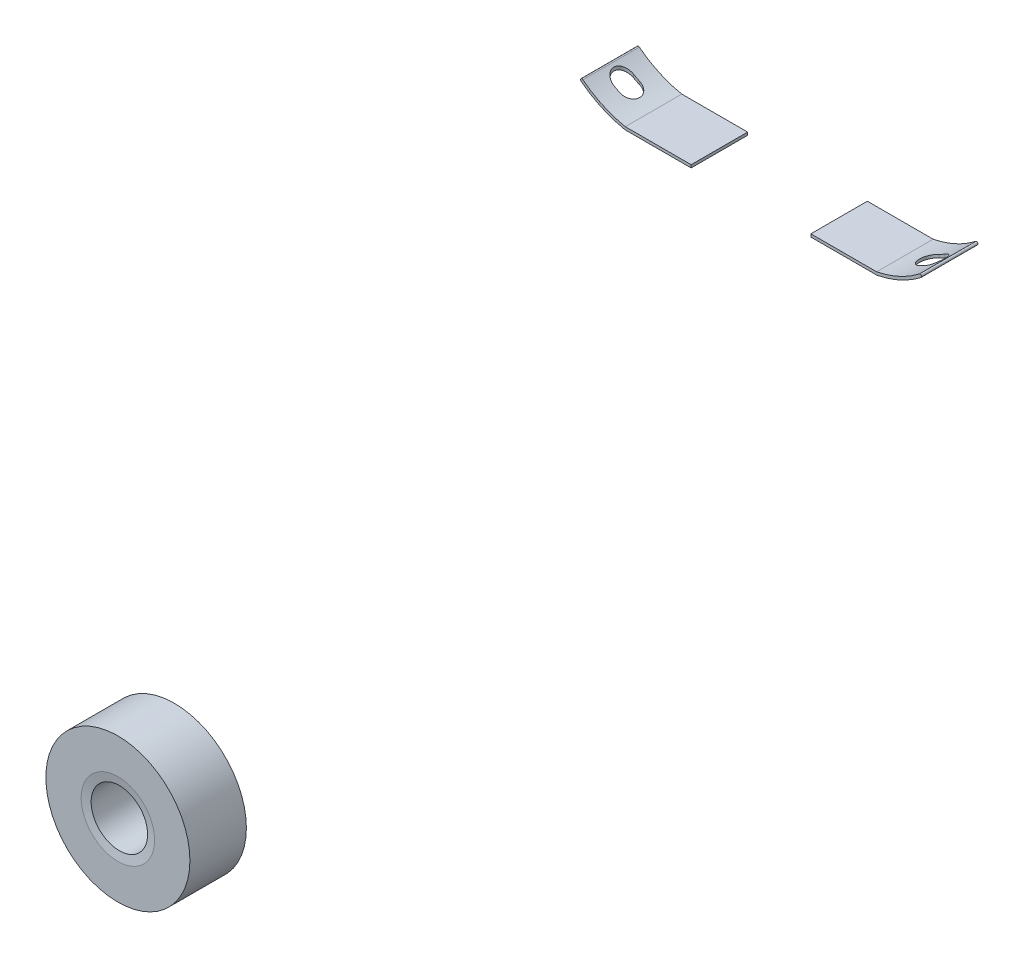
from build123d import *

# Parameters (mm, degrees)
BOSS_EXTRUDE1_DEPTH   = 2
BOSS_EXTRUDE1_2_DEPTH = 2
CUT_EXTRUDE1_DEPTH    = 2
SKETCH3_R             = 2.55
SKETCH3_R_2           = 1
BOSS_EXTRUDE2_DEPTH   = 2
CHAMFER1_SIZE         = 0.3
CHAMFER1_SIZE2        = 0.052898094


with BuildPart() as part:
    # Sketch1 → Boss-Extrude1 (new body)
    with BuildSketch(Plane.XY):
        with BuildLine():
            Line((2.119201361, 7.695095724), (4.458497719, 7.695095724))
            ThreePointArc((4.458497719, 7.695095724), (5.28034288, 7.957709004), (6.018106177, 8.40503497))
            ThreePointArc((6.018106177, 8.40503497), (6.026743298, 8.475216166), (5.956562103, 8.483853287))
            ThreePointArc((5.956562103, 8.483853287), (5.243250103, 8.05070086), (4.448831418, 7.795095724))
            Line((4.448831418, 7.795095724), (2.119201361, 7.795095724))
            Line((2.119201361, 7.795095724), (2.119201361, 7.695095724))
        make_face()
    extrude(amount=BOSS_EXTRUDE1_DEPTH)


with BuildPart() as body_2:
    # Sketch1 → Boss-Extrude1 2 (new body)
    with BuildSketch(Plane.XY):
        with BuildLine():
            Line((-2.119201361, 7.695095724), (-2.119201361, 7.795095724))
            Line((-2.119201361, 7.795095724), (-4.448831418, 7.795095724))
            ThreePointArc((-4.448831418, 7.795095724), (-5.243250103, 8.05070086), (-5.956562103, 8.483853287))
            ThreePointArc((-5.956562103, 8.483853287), (-6.026743298, 8.475216166), (-6.018106177, 8.40503497))
            ThreePointArc((-6.018106177, 8.40503497), (-5.28034288, 7.957709004), (-4.458497719, 7.695095724))
            Line((-4.458497719, 7.695095724), (-2.119201361, 7.695095724))
        make_face()
    extrude(amount=BOSS_EXTRUDE1_2_DEPTH)


with BuildPart() as cut_extrude1_tool:
    # Sketch2 → Cut-Extrude1 (new body)
    with BuildSketch(Plane.XZ.offset(-7.695095724)):
        with BuildLine():
            Line((5.30218152, 0.638571522), (5.512812284, 0.638571522))
            ThreePointArc((5.512812284, 0.638571522), (5.862812284, 0.988571522), (5.512812284, 1.338571522))
            Line((5.512812284, 1.338571522), (5.30218152, 1.338571522))
            ThreePointArc((5.30218152, 1.338571522), (4.95218152, 0.988571522), (5.30218152, 0.638571522))
        make_face()
        with BuildLine():
            Line((-5.30218152, 1.338571522), (-5.512812284, 1.338571522))
            ThreePointArc((-5.512812284, 1.338571522), (-5.862812284, 0.988571522), (-5.512812284, 0.638571522))
            Line((-5.512812284, 0.638571522), (-5.30218152, 0.638571522))
            ThreePointArc((-5.30218152, 0.638571522), (-4.95218152, 0.988571522), (-5.30218152, 1.338571522))
        make_face()
    extrude(amount=-CUT_EXTRUDE1_DEPTH)


with BuildPart() as part_1:
    add(part.part)

    # Cut-Extrude1: cut by cut_extrude1_tool
    add(cut_extrude1_tool.part, mode=Mode.SUBTRACT)


with BuildPart() as body_2_1:
    add(body_2.part)

    # Cut-Extrude1: cut by cut_extrude1_tool
    add(cut_extrude1_tool.part, mode=Mode.SUBTRACT)


with BuildPart() as body_3:
    # Sketch3 → Boss-Extrude2 (new body)
    with BuildSketch(Plane.XY.offset(24.416132501)):
        Circle(SKETCH3_R)
        Circle(SKETCH3_R_2, mode=Mode.SUBTRACT)
    extrude(amount=-BOSS_EXTRUDE2_DEPTH)

    # Chamfer1
    chamfer1_edges = [body_3.edges().sort_by_distance(p)[0] for p in [
        (-1, 0, 24.416132501),
    ]]
    chamfer1_side = [body_3.faces().sort_by_distance(p)[0] for p in [
        (-2.477875108, 0, 24.416132501),
    ]]
    chamfer(chamfer1_edges, length=CHAMFER1_SIZE, length2=CHAMFER1_SIZE2, reference=chamfer1_side[0])


solid = Compound([part_1.part, body_2_1.part, body_3.part])
